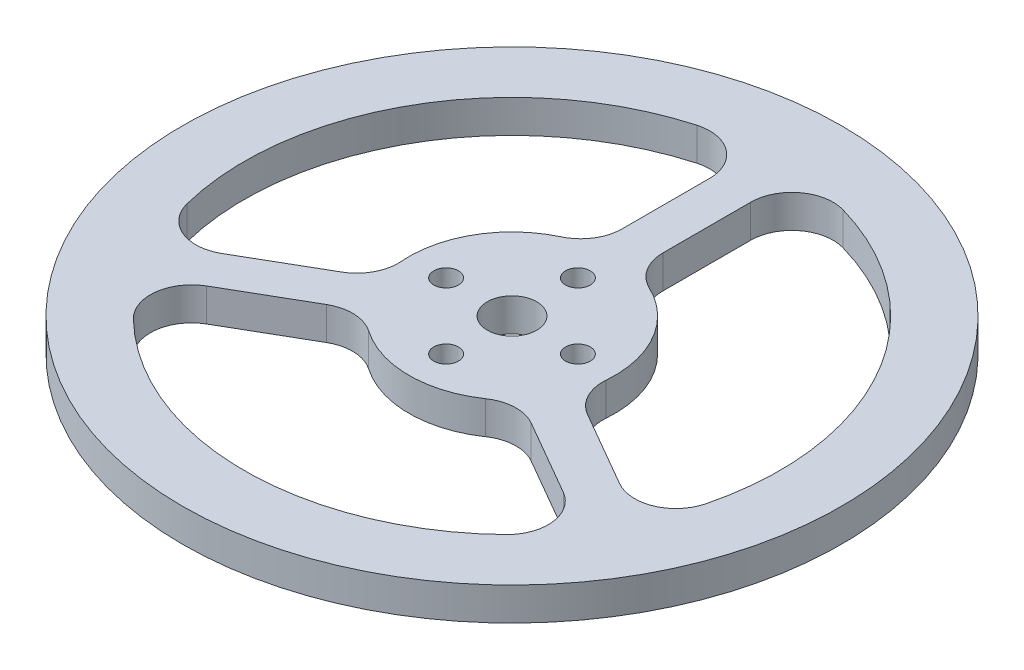
from build123d import *

# Parameters (mm, degrees)
SKETCH_1_R          = 40
EXTRUDE_1_DEPTH     = 4
SKETCH_2_R          = 1.5
SKETCH_2_R_2        = 3
CUT_EXTRUDE_1_DEPTH = 5
CUT_EXTRUDE_2_DEPTH = 10
FILLET_1_R          = 5


with BuildPart() as part:
    # 草图1 → 凸台-拉伸1 (new body)
    with BuildSketch(Plane(origin=(0, 0, 0), x_dir=(1, 0, 0), z_dir=(0, 1, 0))):
        Circle(SKETCH_1_R)
    extrude(amount=EXTRUDE_1_DEPTH)

    # 草图2 → 切除-拉伸1 (cut, through all)
    with BuildSketch(Plane(origin=(0, 4, 0), x_dir=(1, 0, 0), z_dir=(0, 1, 0))):
        with Locations((8, 0)):
            Circle(SKETCH_2_R)
        with Locations((0, 8)):
            Circle(SKETCH_2_R)
        with Locations((-8, 0)):
            Circle(SKETCH_2_R)
        with Locations((0, -8)):
            Circle(SKETCH_2_R)
        Circle(SKETCH_2_R_2)
    extrude(amount=-CUT_EXTRUDE_1_DEPTH, mode=Mode.SUBTRACT)

    # 草图3 → 切除-拉伸2 (cut)
    with BuildSketch(Plane(origin=(0, 4, 0), x_dir=(1, 0, 0), z_dir=(0, 1, 0))):
        with BuildLine():
            Line((-29.324463582, -14.011632155), (-11.86555962, -3.931729252))
            ThreePointArc((-11.86555962, -3.931729252), (-10.811101802, 6.274557978), (-2.472197603, 12.253090998))
            Line((-2.472197603, 12.253090998), (-2.472197603, 32.405836496))
            ThreePointArc((-2.472197603, 32.405836496), (-28.131872753, 16.274143154), (-29.324463582, -14.011632155))
        make_face()
        with BuildLine():
            ThreePointArc((12.5, 0), (12.335818498, -2.019302353), (11.847586881, -3.985559571))
            Line((11.847586881, -3.985559571), (29.300376438, -14.06193232))
            ThreePointArc((29.300376438, -14.06193232), (31.69000027, -7.210678392), (32.5, 0))
            ThreePointArc((32.5, 0), (23.857950225, 22.069168789), (2.527802397, 32.401546492))
            Line((2.527802397, 32.401546492), (2.527802397, 12.241740687))
            ThreePointArc((2.527802397, 12.241740687), (9.691427396, 7.894696639), (12.5, 0))
        make_face()
        with BuildLine():
            Line((26.796661185, -18.389914337), (9.337757223, -8.310011435))
            ThreePointArc((9.337757223, -8.310011435), (-0.028375705, -12.499967793), (-9.375389278, -8.267531427))
            Line((-9.375389278, -8.267531427), (-26.828178835, -18.343904176))
            ThreePointArc((-26.828178835, -18.343904176), (-0.027885019, -32.499988037), (26.796661185, -18.389914337))
        make_face()
    extrude(amount=-CUT_EXTRUDE_2_DEPTH, mode=Mode.SUBTRACT)

    # 圆角1
    fillet_1_edges = [part.edges().sort_by_distance(p)[0] for p in [
        (11.847586881, 2, 3.985559571),
        (2.527802397, 2, -12.241740687),
        (2.527802397, 2, -32.401546492),
        (29.300376438, 2, 14.06193232),
        (-9.375389278, 2, 8.267531427),
        (9.337757223, 2, 8.310011435),
        (26.796661185, 2, 18.389914337),
        (-26.828178835, 2, 18.343904176),
        (-2.472197603, 2, -12.253090998),
        (-11.86555962, 2, 3.931729252),
        (-29.324463582, 2, 14.011632155),
        (-2.472197603, 2, -32.405836496),
    ]]
    fillet(fillet_1_edges, radius=FILLET_1_R)


solid = part.part
